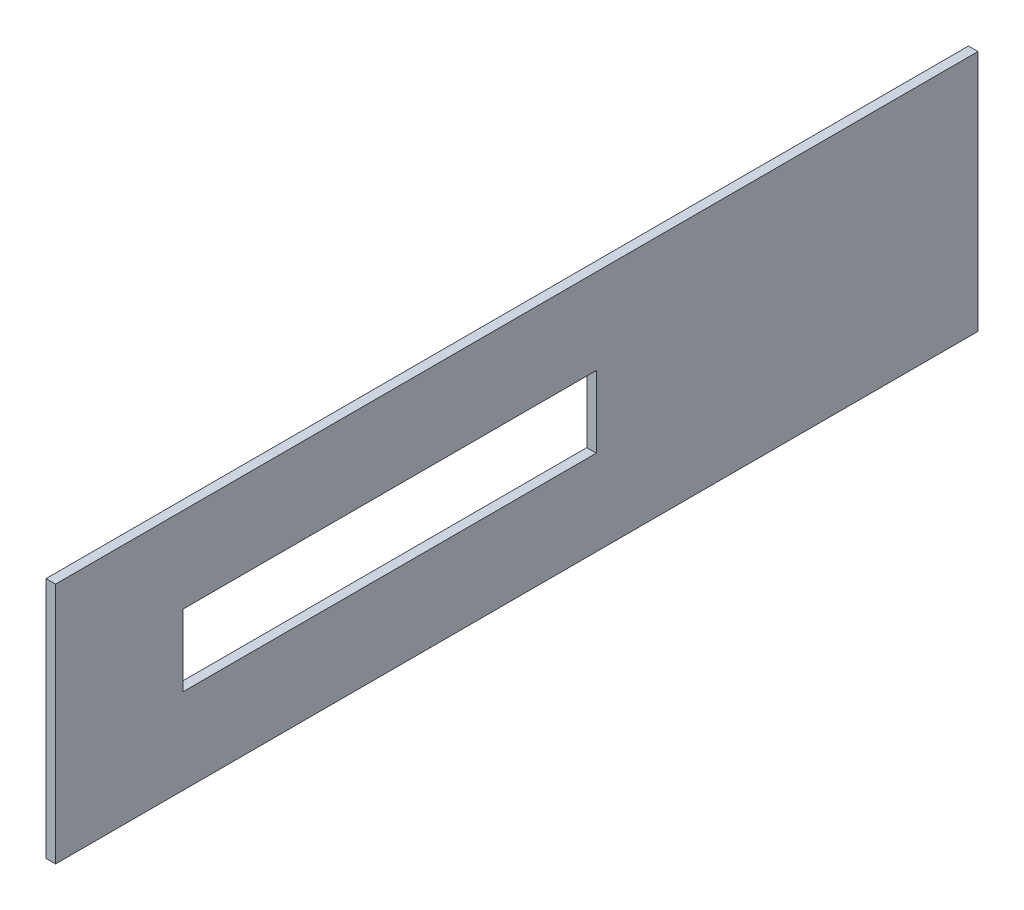
from build123d import *

# Parameters (mm, degrees)
SKETCH1_W           = 290
SKETCH1_H           = 76.2
BOSS_EXTRUDE1_DEPTH = 3
SKETCH2_W           = 130
SKETCH2_H           = 22.5
CUT_EXTRUDE1_DEPTH  = 4


with BuildPart() as part:
    # Sketch1 → Boss-Extrude1 (new body)
    with BuildSketch(Plane(origin=(0, 0, 0), x_dir=(0, 0, -1), z_dir=(1, 0, 0))):
        Rectangle(SKETCH1_W, SKETCH1_H)
    extrude(amount=BOSS_EXTRUDE1_DEPTH)

    # Sketch2 → Cut-Extrude1 (cut, through all)
    with BuildSketch(Plane(origin=(3, 0, 0), x_dir=(0, 0, -1), z_dir=(1, 0, 0))):
        with Locations((-40, 0)):
            Rectangle(SKETCH2_W, SKETCH2_H)
    extrude(amount=-CUT_EXTRUDE1_DEPTH, mode=Mode.SUBTRACT)


solid = part.part
